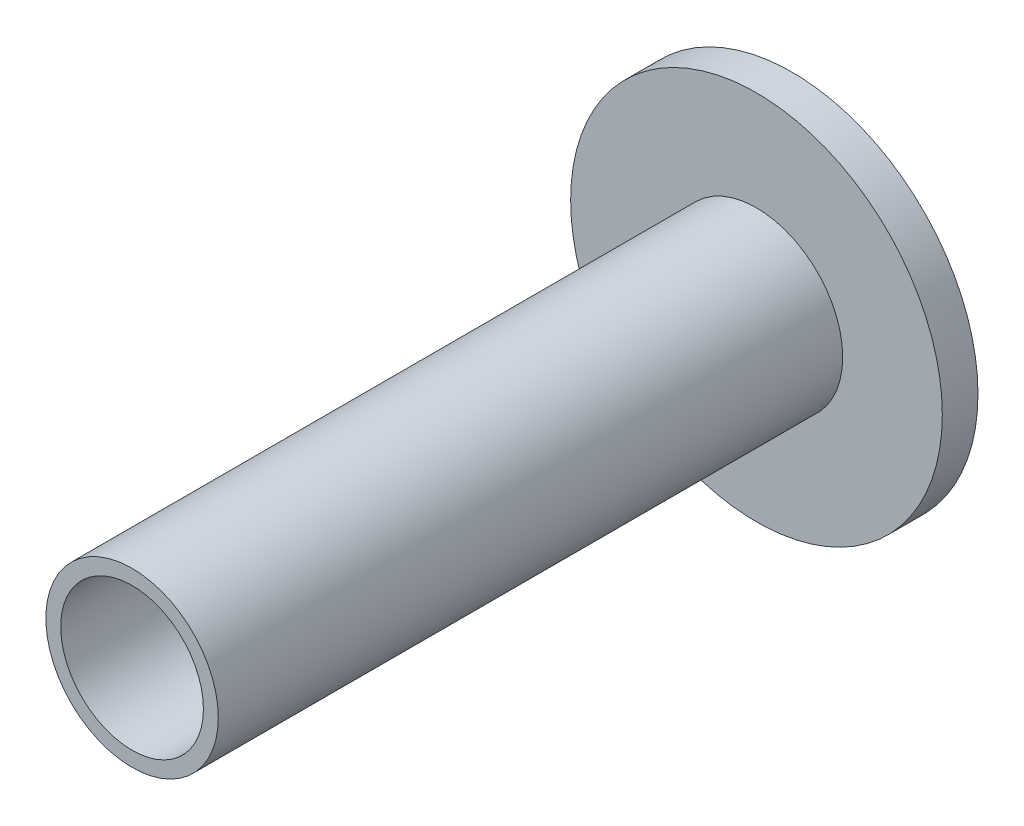
from build123d import *

# Parameters (mm, degrees)
SKETCH1_R           = 29
SKETCH1_R_2         = 24
BOSS_EXTRUDE1_DEPTH = 210
SKETCH2_R           = 62.5
SKETCH2_R_2         = 23.706605619
BOSS_EXTRUDE2_DEPTH = 12


with BuildPart() as part:
    # Sketch1 → Boss-Extrude1 (new body)
    with BuildSketch(Plane.XY):
        Circle(SKETCH1_R)
        Circle(SKETCH1_R_2, mode=Mode.SUBTRACT)
    extrude(amount=BOSS_EXTRUDE1_DEPTH)

    # Sketch2 → Boss-Extrude2 (add)
    with BuildSketch(Plane(origin=(0, 0, 0), x_dir=(-1, 0, 0), z_dir=(0, 0, -1))):
        Circle(SKETCH2_R)
        Circle(SKETCH2_R_2, mode=Mode.SUBTRACT)
    extrude(amount=BOSS_EXTRUDE2_DEPTH)


solid = part.part
